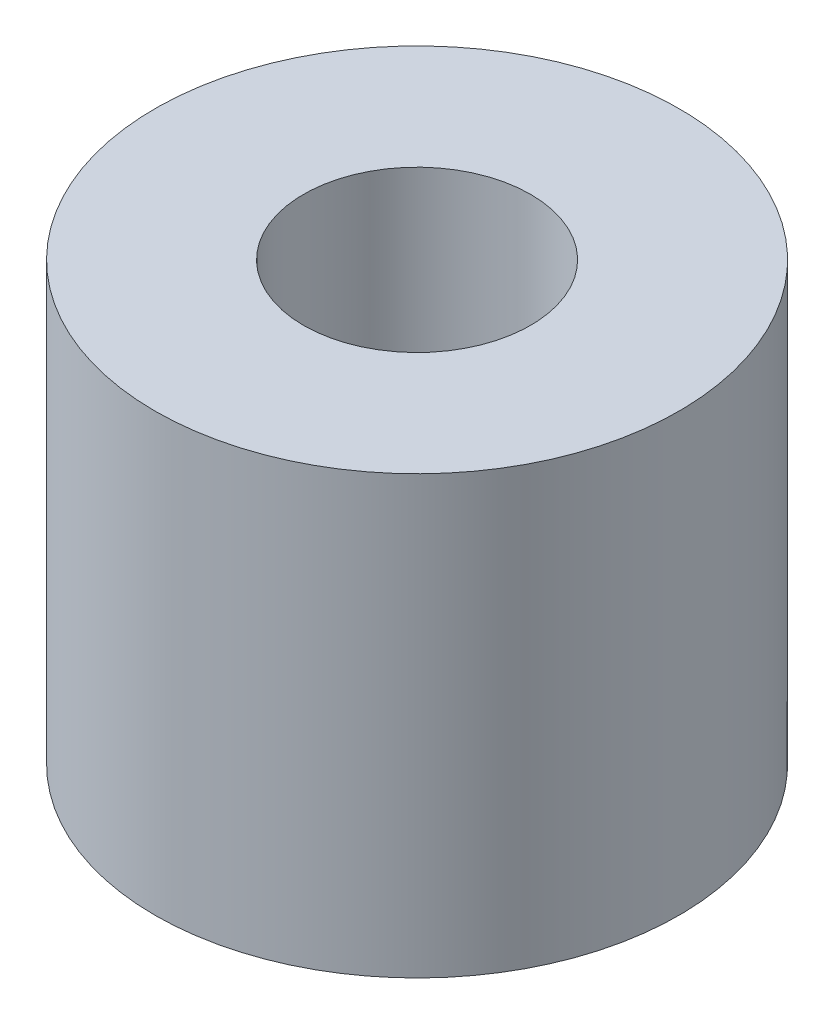
from build123d import *

# Parameters (mm, degrees)
SKETCH1_R           = 3
SKETCH1_R_2         = 1.3
BOSS_EXTRUDE1_DEPTH = 5


with BuildPart() as part:
    # Sketch1 → Boss-Extrude1 (new body)
    with BuildSketch(Plane(origin=(0, 0, 0), x_dir=(1, 0, 0), z_dir=(0, 1, 0))):
        Circle(SKETCH1_R)
        Circle(SKETCH1_R_2, mode=Mode.SUBTRACT)
    extrude(amount=BOSS_EXTRUDE1_DEPTH)


solid = part.part
